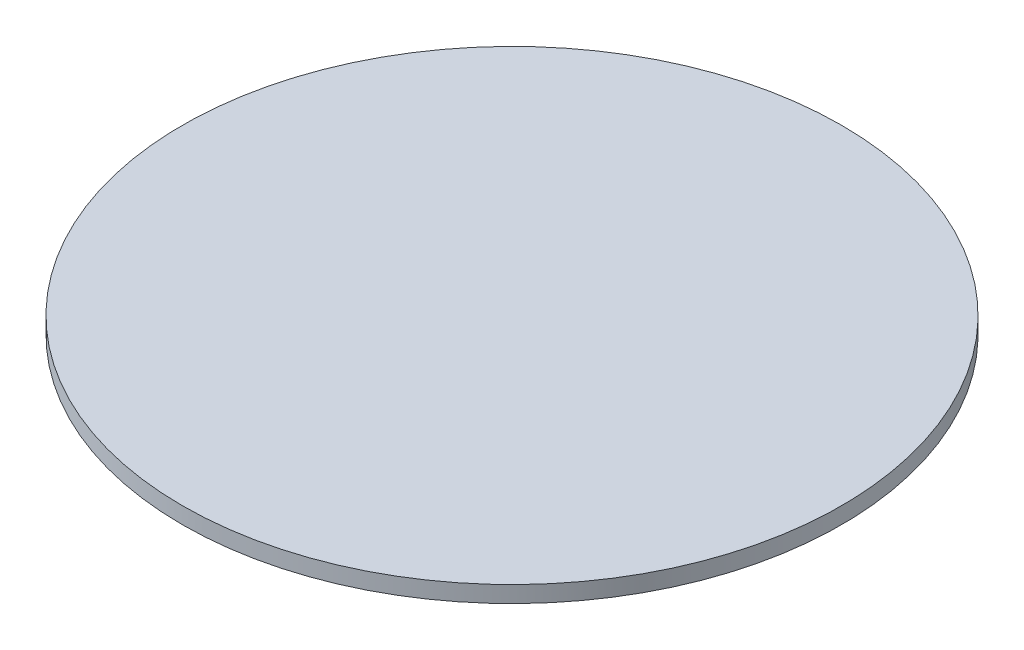
from build123d import *

# Parameters (mm, degrees)
SKETCH1_R           = 127
BOSS_EXTRUDE1_DEPTH = 6.35


with BuildPart() as part:
    # Sketch1 → Boss-Extrude1 (new body)
    with BuildSketch(Plane(origin=(0, 0, 0), x_dir=(1, 0, 0), z_dir=(0, 1, 0))):
        Circle(SKETCH1_R)
    extrude(amount=BOSS_EXTRUDE1_DEPTH)


solid = part.part
